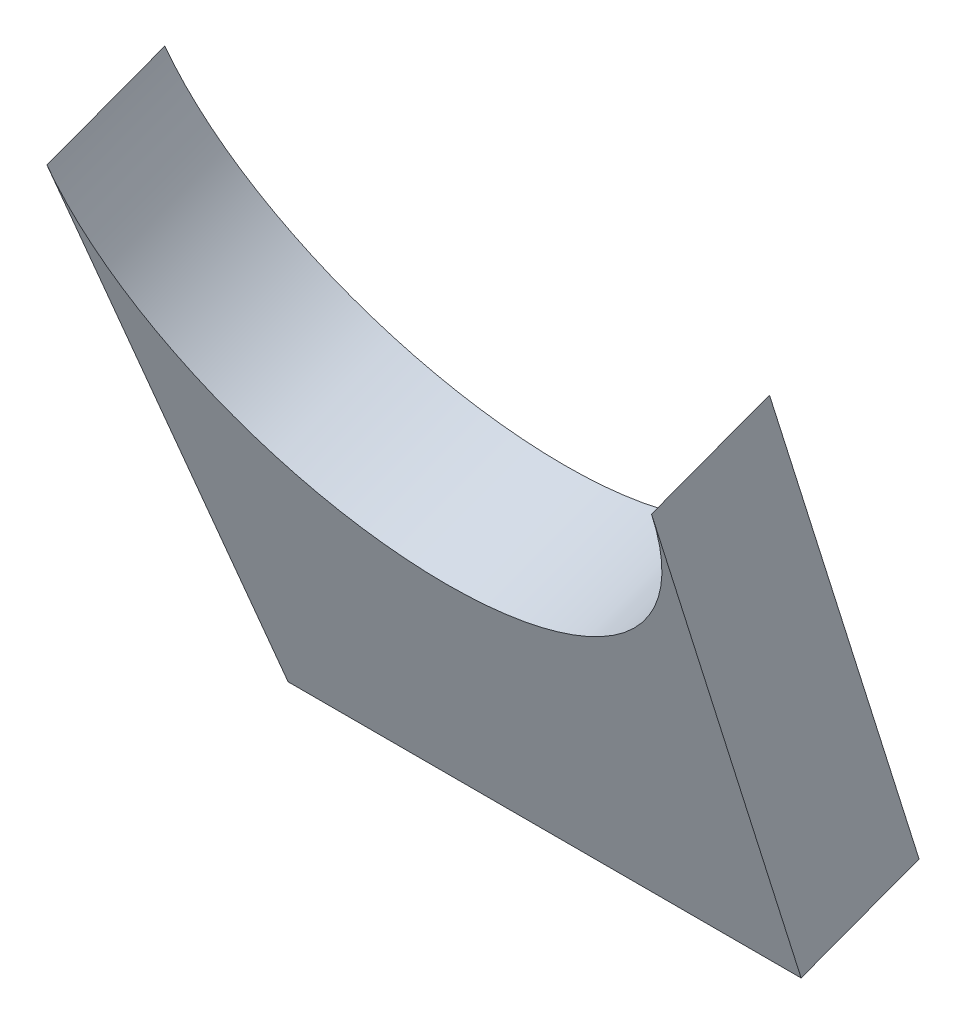
from build123d import *

# Parameters (mm, degrees)
BOSS_EXTRUDE3_DEPTH = 34.29


with BuildPart() as part:
    # Sketch4 → Boss-Extrude3 (new body)
    with BuildSketch(Plane(origin=(0, -48.929027825, 130.802863094), x_dir=(1, 0, 0), z_dir=(0, -0.350357155, 0.936616177))):
        with BuildLine():
            Line((64.525230348, 336.071016896), (77.001077593, 184.182527419))
            Line((77.001077593, 184.182527419), (216.701077593, 184.182527419))
            Line((216.701077593, 184.182527419), (229.176924838, 336.071016896))
            ThreePointArc((229.176924838, 336.071016896), (146.851077593, 260.230020219), (64.525230348, 336.071016896))
        make_face()
    extrude(amount=BOSS_EXTRUDE3_DEPTH)


solid = part.part
